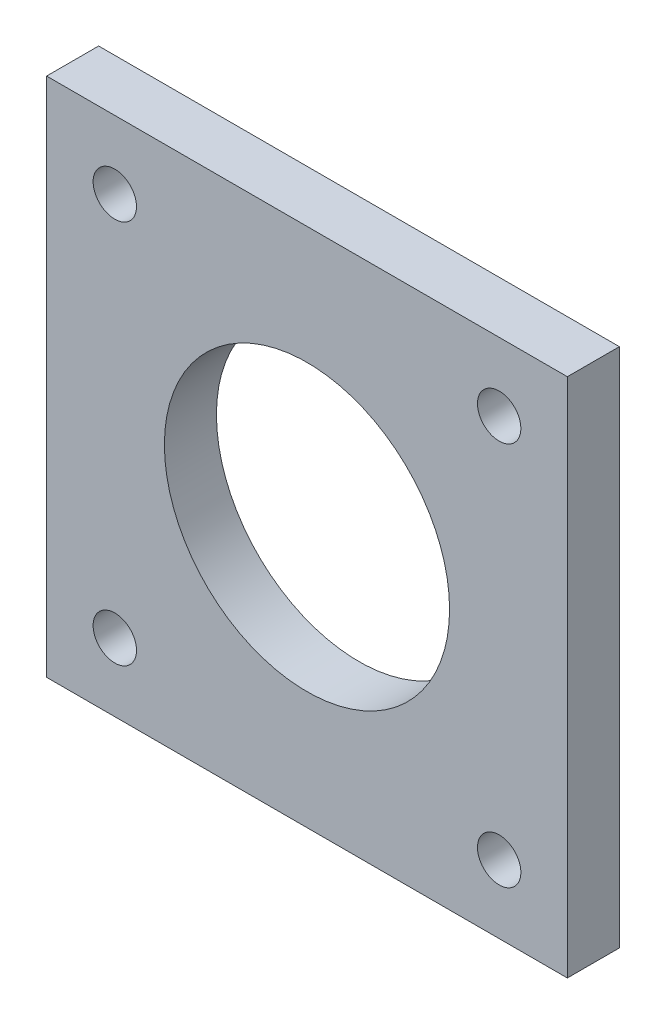
from build123d import *

# Parameters (mm, degrees)
SKETCH1_W           = 42
SKETCH1_H           = 42
SKETCH1_R           = 11.5
SKETCH1_R_2         = 1.75
BOSS_EXTRUDE1_DEPTH = 4.19608


with BuildPart() as part:
    # Sketch1 → Boss-Extrude1 (new body)
    with BuildSketch(Plane.XY):
        Rectangle(SKETCH1_W, SKETCH1_H)
        Circle(SKETCH1_R, mode=Mode.SUBTRACT)
        with Locations((-15.5, 15.5)):
            Circle(SKETCH1_R_2, mode=Mode.SUBTRACT)
        with Locations((15.5, 15.5)):
            Circle(SKETCH1_R_2, mode=Mode.SUBTRACT)
        with Locations((15.5, -15.5)):
            Circle(SKETCH1_R_2, mode=Mode.SUBTRACT)
        with Locations((-15.5, -15.5)):
            Circle(SKETCH1_R_2, mode=Mode.SUBTRACT)
    extrude(amount=BOSS_EXTRUDE1_DEPTH)


solid = part.part
